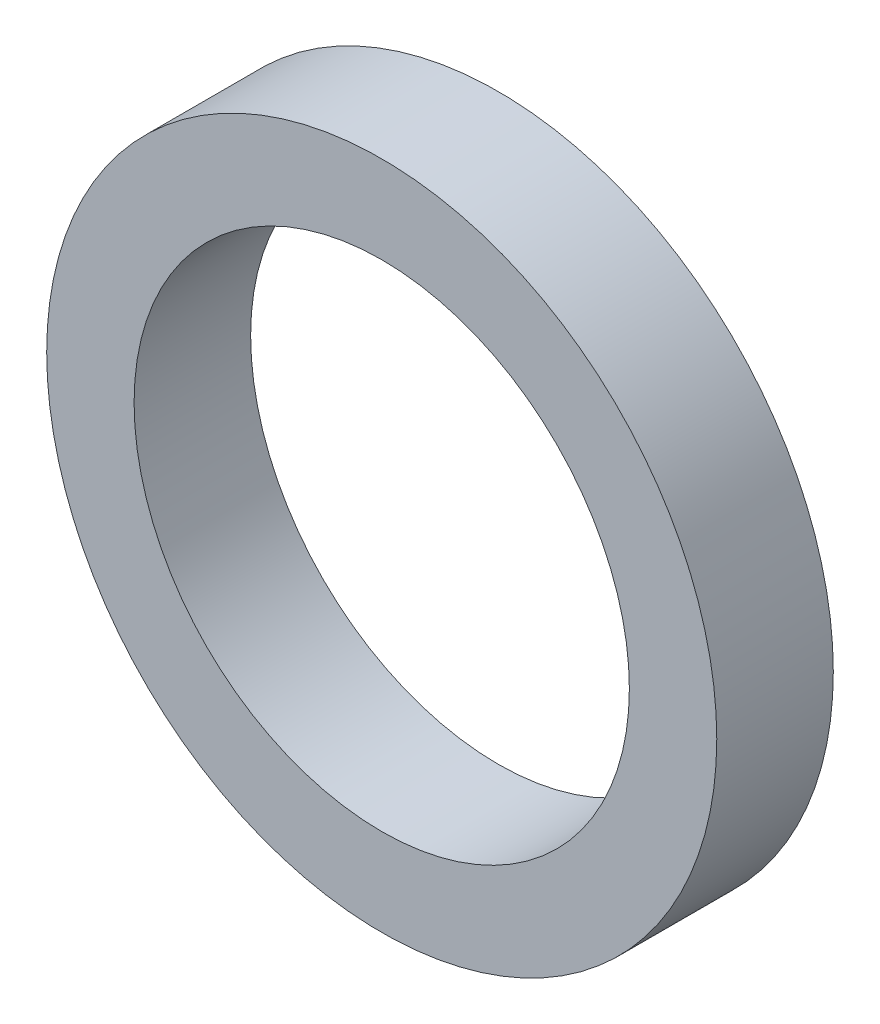
from build123d import *

# Parameters (mm, degrees)
SKETCH_1_R      = 11.5
SKETCH_1_R_2    = 8.5
EXTRUDE_1_DEPTH = 4


with BuildPart() as part:
    # 草图1 → 凸台-拉伸1 (new body)
    with BuildSketch(Plane.XY):
        Circle(SKETCH_1_R)
        Circle(SKETCH_1_R_2, mode=Mode.SUBTRACT)
    extrude(amount=EXTRUDE_1_DEPTH)


solid = part.part
